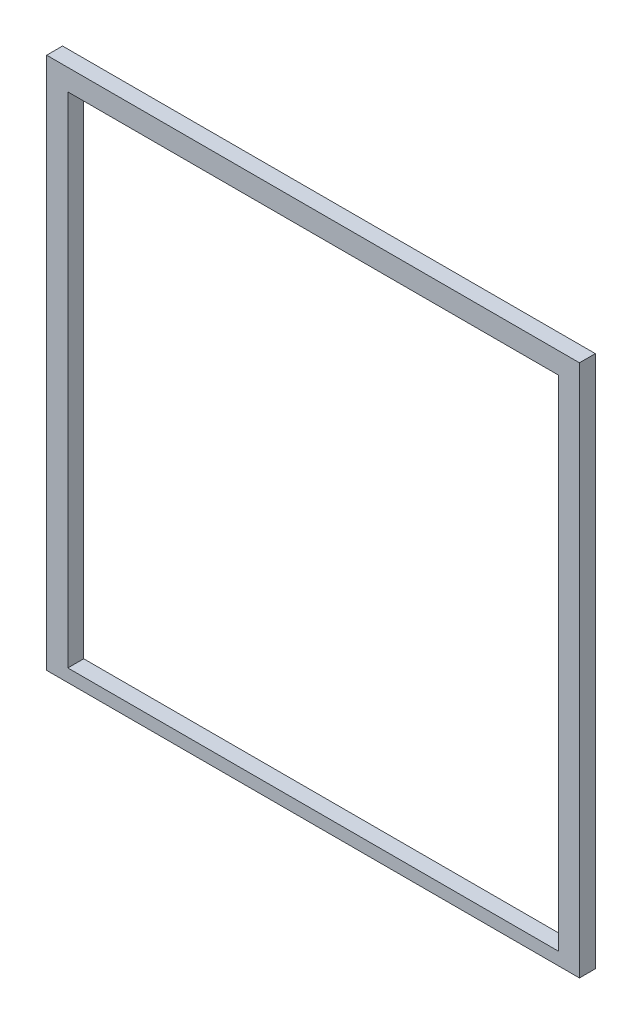
from build123d import *

# Parameters (mm, degrees)
SKETCH1_W           = 503
SKETCH1_H           = 503
SKETCH1_W_2         = 463
SKETCH1_H_2         = 471
BOSS_EXTRUDE1_DEPTH = 15


with BuildPart() as part:
    # Sketch1 → Boss-Extrude1 (new body)
    with BuildSketch(Plane.XY):
        with Locations((251.5, 251.5)):
            Rectangle(SKETCH1_W, SKETCH1_H)
        with Locations((251.5, 247.5)):
            Rectangle(SKETCH1_W_2, SKETCH1_H_2, mode=Mode.SUBTRACT)
    extrude(amount=BOSS_EXTRUDE1_DEPTH)


solid = part.part
